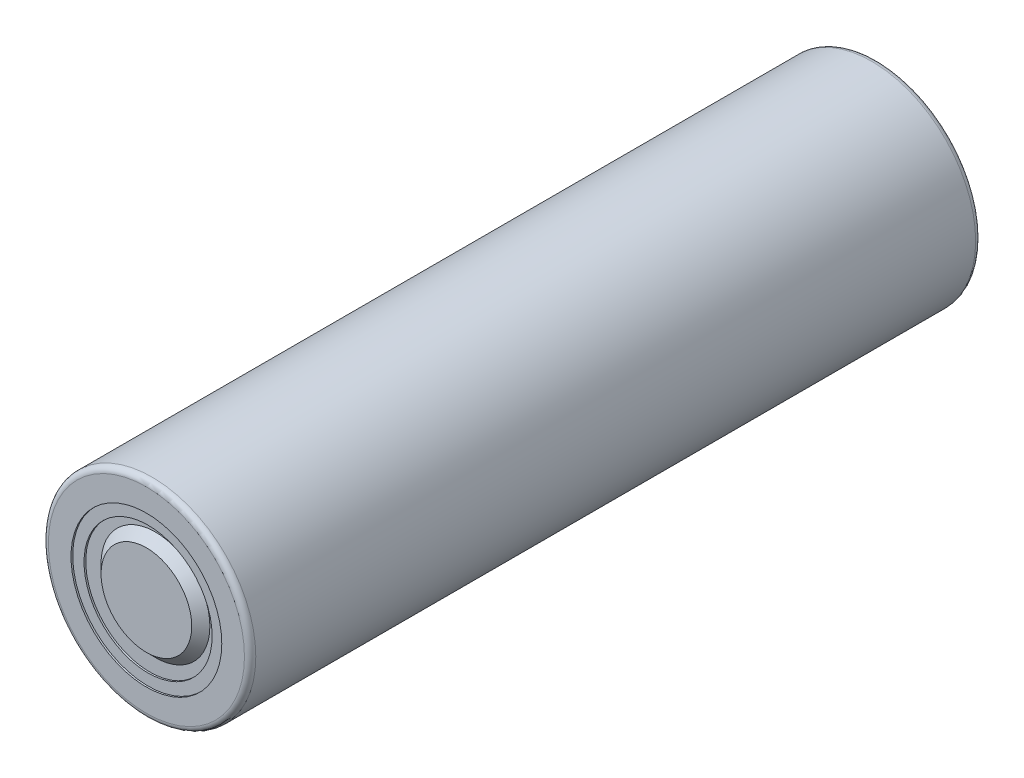
from build123d import *

# Parameters (mm, degrees)
SKETCH1_R           = 9.149999998
BOSS_EXTRUDE1_DEPTH = 64.5
SKETCH2_R           = 7.15
CUT_EXTRUDE1_DEPTH  = 0.2
FILLET1_R           = 0.5


with BuildPart() as part:
    # Sketch1 → Boss-Extrude1 (new body)
    with BuildSketch(Plane.XY):
        Circle(SKETCH1_R)
    extrude(amount=BOSS_EXTRUDE1_DEPTH)

    # Sketch2 → Cut-Extrude1 (cut)
    with BuildSketch(Plane.XY):
        Circle(SKETCH2_R)
    extrude(amount=CUT_EXTRUDE1_DEPTH, mode=Mode.SUBTRACT)

    # Sketch3 → Cut-Revolve1 (revolve, cut)
    with BuildSketch(Plane(origin=(0, 0, 0), x_dir=(1, 0, 0), z_dir=(0, 1, 0))):
        Polygon((-8.149999999, -64.2), (-8.149999999, -63.700000001), (-4.799999999, -63.700000001), (-3.999999999, -64.5), (-6.650000001, -64.5), (-6.650000001, -64.35), (-5.649999999, -64.35), (-5.649999999, -64.2), align=None)
    revolve(axis=Axis((0, 0, 64.835920194), (0, 0, -1)), mode=Mode.SUBTRACT)

    # Fillet1
    fillet1_edges = [part.edges().sort_by_distance(p)[0] for p in [
        (-9.149999998, 0, 0),
        (-9.149999998, 0, 64.5),
    ]]
    fillet(fillet1_edges, radius=FILLET1_R)


solid = part.part
